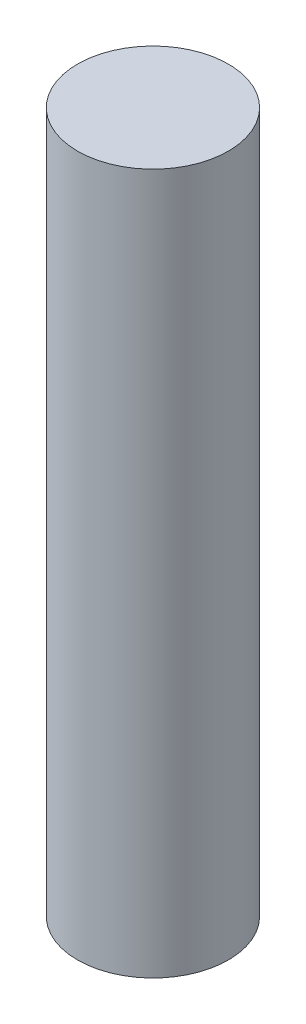
from build123d import *

# Parameters (mm, degrees)
SKETCH1_R           = 1.4
BOSS_EXTRUDE1_DEPTH = 10
SKETCH2_R           = 1.4
BOSS_EXTRUDE2_DEPTH = 3


with BuildPart() as part:
    # Sketch1 → Boss-Extrude1 (new body)
    with BuildSketch(Plane(origin=(0, 0, 0), x_dir=(1, 0, 0), z_dir=(0, 1, 0))):
        Circle(SKETCH1_R)
    extrude(amount=BOSS_EXTRUDE1_DEPTH)

    # Sketch2 → Boss-Extrude2 (add)
    with BuildSketch(Plane(origin=(0, 10, 0), x_dir=(1, 0, 0), z_dir=(0, 1, 0))):
        Circle(SKETCH2_R)
    extrude(amount=BOSS_EXTRUDE2_DEPTH)


solid = part.part
